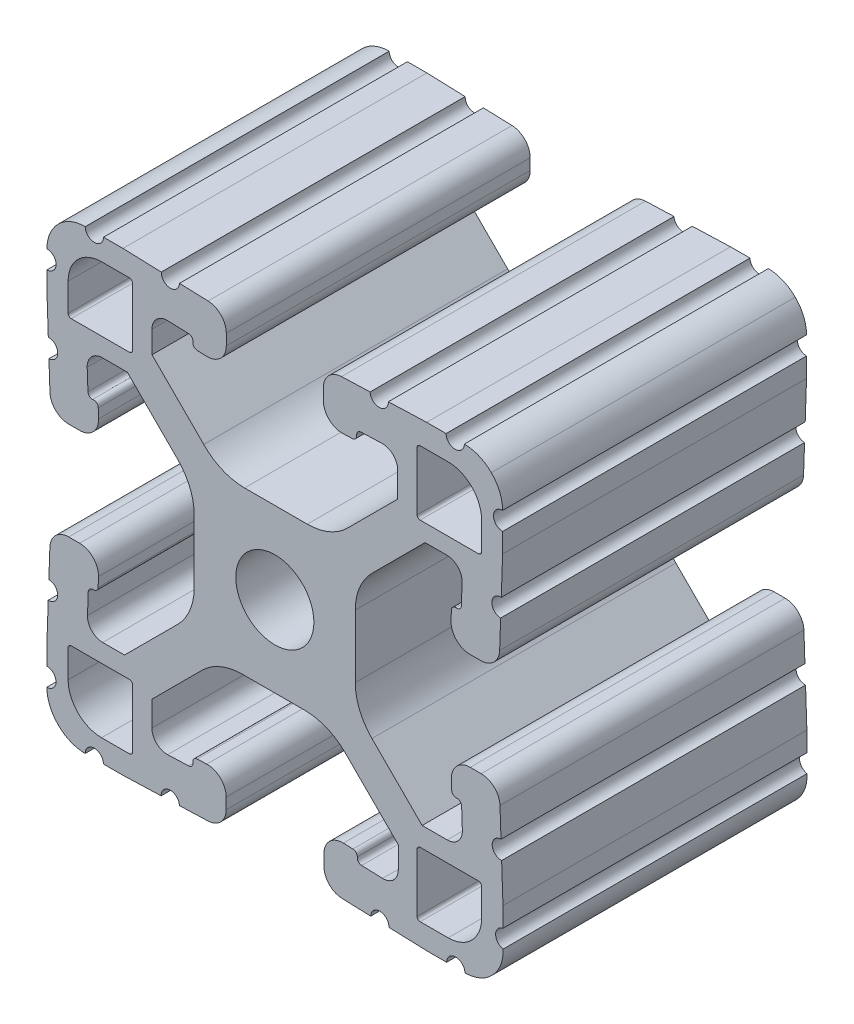
from build123d import *

# Parameters (mm, degrees)
SKETCH1_R           = 3.2639
BOSS_EXTRUDE1_DEPTH = 25.4


with BuildPart() as part:
    # Sketch1 → Boss-Extrude1 (new body)
    with BuildSketch(Plane(origin=(0, 0, -25.4), x_dir=(-1, 0, 0), z_dir=(0, 0, -1))):
        with BuildLine():
            Line((-88.043721549, 91.862643967), (-86.29674679, 91.923648859))
            ThreePointArc((-86.29674679, 91.923648859), (-85.370208675, 91.567983831), (-84.982425017, 90.654422489))
            Line((-84.982425017, 90.654422489), (-84.982425017, 88.800173916))
            Line((-84.982425017, 88.800173916), (-89.306565884, 84.476033049))
            ThreePointArc((-89.306565884, 84.476033049), (-90.866149908, 83.406077005), (-92.719610366, 83.029523439))
            Line((-92.719610366, 83.029523439), (-97.961628589, 83.029523439))
            ThreePointArc((-97.961628589, 83.029523439), (-99.779298356, 83.391080435), (-101.320244378, 84.42070765))
            Line((-101.320244378, 84.42070765), (-105.516001761, 88.616465033))
            Line((-105.516001761, 88.616465033), (-105.516001761, 90.731330035))
            ThreePointArc((-105.516001761, 90.731330035), (-105.128218103, 91.644891377), (-104.201679988, 92.000556406))
            Line((-104.201679988, 92.000556406), (-102.454705229, 91.939551513))
            ThreePointArc((-102.454705229, 91.939551513), (-102.193933359, 91.823448504), (-102.087001761, 91.558783602))
            ThreePointArc((-102.087001761, 91.558783602), (-102.010859042, 91.249291513), (-101.726191901, 91.105946874))
            Line((-101.726191901, 91.105946874), (-100.929727576, 91.078102142))
            ThreePointArc((-100.929727576, 91.078102142), (-99.780779944, 91.519102656), (-99.299905511, 92.651940638))
            Line((-99.299905511, 92.651940638), (-99.299905511, 93.566848638))
            ThreePointArc((-99.299905511, 93.566848638), (-99.741889517, 94.660796975), (-100.819746715, 95.140689345))
            Line((-100.819746715, 95.140689345), (-103.211918901, 95.224224422))
            ThreePointArc((-103.211918901, 95.224224422), (-104.000045777, 94.489281495), (-104.734990687, 95.277406522))
            Line((-104.734990687, 95.277406522), (-107.935905676, 95.389166912))
            Line((-107.935905676, 95.389166912), (-109.561454876, 95.389166912))
            ThreePointArc((-109.561454876, 95.389166912), (-110.323454876, 94.627166912), (-111.085454876, 95.389166912))
            ThreePointArc((-111.085454876, 95.389166912), (-112.308767787, 95.144035599), (-113.343184761, 94.446493225))
            ThreePointArc((-113.343184761, 94.446493225), (-114.04072548, 93.412075135), (-114.285854836, 92.188761832))
            ThreePointArc((-114.285854836, 92.188761832), (-113.523853616, 91.426762441), (-114.285853616, 90.664761832))
            Line((-114.285853616, 90.664761832), (-114.285853616, 89.039212632))
            Line((-114.285853616, 89.039212632), (-114.174093219, 85.838297643))
            ThreePointArc((-114.174093219, 85.838297643), (-113.385968191, 85.103352735), (-114.120911115, 84.315225857))
            Line((-114.120911115, 84.315225857), (-114.037376031, 81.923053667))
            ThreePointArc((-114.037376031, 81.923053667), (-113.55748366, 80.845196472), (-112.463535325, 80.403212468))
            Line((-112.463535325, 80.403212468), (-111.548627325, 80.403212468))
            ThreePointArc((-111.548627325, 80.403212468), (-110.415788905, 80.884087354), (-109.974788872, 82.033035791))
            Line((-109.974788872, 82.033035791), (-110.002634241, 82.829500094))
            ThreePointArc((-110.002634241, 82.829500094), (-110.118742417, 83.090261917), (-110.383401914, 83.197188))
            ThreePointArc((-110.383401914, 83.197188), (-110.693757401, 83.272605688), (-110.837665276, 83.557735272))
            Line((-110.837665276, 83.557735272), (-110.898671566, 85.304709982))
            ThreePointArc((-110.898671566, 85.304709982), (-110.543006925, 86.231248747), (-109.62944523, 86.61903277))
            Line((-109.62944523, 86.61903277), (-107.807161806, 86.61903277))
            Line((-107.807161806, 86.61903277), (-103.364925613, 82.176810793))
            ThreePointArc((-103.364925613, 82.176810793), (-102.335294479, 80.635862907), (-101.973736029, 78.81818963))
            Line((-101.973736029, 78.81818963), (-101.973736029, 73.576034207))
            ThreePointArc((-101.973736029, 73.576034207), (-102.335293752, 71.758362684), (-103.364922926, 70.21741573))
            Line((-103.364922926, 70.21741573), (-107.560683666, 66.021661704))
            Line((-107.560683666, 66.021661704), (-109.652436558, 66.021661704))
            ThreePointArc((-109.652436558, 66.021661704), (-110.565998503, 66.409445617), (-110.921663765, 67.335984343))
            Line((-110.921663765, 67.335984343), (-110.860658873, 69.082959102))
            ThreePointArc((-110.860658873, 69.082959102), (-110.744555864, 69.343730973), (-110.479890961, 69.45066257))
            ThreePointArc((-110.479890961, 69.45066257), (-110.173494703, 69.529390272), (-110.032185196, 69.812424443))
            Line((-110.032185196, 69.812424443), (-110.004340464, 70.608888768))
            ThreePointArc((-110.004340464, 70.608888768), (-110.445340978, 71.7578364), (-111.57817896, 72.238710833))
            Line((-111.57817896, 72.238710833), (-112.49308696, 72.238710833))
            ThreePointArc((-112.49308696, 72.238710833), (-113.587035297, 71.796726827), (-114.066927667, 70.718869629))
            Line((-114.066927667, 70.718869629), (-114.150462744, 68.326697443))
            ThreePointArc((-114.150462744, 68.326697443), (-113.415519817, 67.538570567), (-114.203644843, 66.803625657))
            Line((-114.203644843, 66.803625657), (-114.315405233, 63.602710668))
            Line((-114.315405233, 63.602710668), (-114.315405233, 61.962557497))
            ThreePointArc((-114.315405233, 61.962557497), (-113.701927281, 61.206106537), (-114.333208228, 60.464447842))
            ThreePointArc((-114.333208228, 60.464447842), (-114.113020459, 59.176546471), (-113.392816136, 58.086372941))
            ThreePointArc((-113.392816136, 58.086372941), (-112.358398046, 57.388832223), (-111.135084743, 57.143702867))
            ThreePointArc((-111.135084743, 57.143702867), (-110.373085352, 57.905704086), (-109.611084743, 57.143704086))
            Line((-109.611084743, 57.143704086), (-107.985535543, 57.143704086))
            Line((-107.985535543, 57.143704086), (-104.784620554, 57.255464483))
            ThreePointArc((-104.784620554, 57.255464483), (-104.049675645, 58.04358951), (-103.261548768, 57.308646586))
            Line((-103.261548768, 57.308646586), (-100.869376578, 57.39218167))
            ThreePointArc((-100.869376578, 57.39218167), (-99.791519383, 57.872074041), (-99.349535378, 58.966022376))
            Line((-99.349535378, 58.966022376), (-99.349535378, 59.880930376))
            ThreePointArc((-99.349535378, 59.880930376), (-99.830409811, 61.013768358), (-100.979357443, 61.454768873))
            Line((-100.979357443, 61.454768873), (-101.775821768, 61.42692414))
            ThreePointArc((-101.775821768, 61.42692414), (-102.036583684, 61.310816174), (-102.143509978, 61.046156762))
            ThreePointArc((-102.143509978, 61.046156762), (-102.222494916, 60.740061862), (-102.505377386, 60.598958297))
            Line((-102.505377386, 60.598958297), (-104.252352145, 60.537953405))
            ThreePointArc((-104.252352145, 60.537953405), (-105.17889026, 60.893618433), (-105.566673918, 61.807179775))
            Line((-105.566673918, 61.807179775), (-105.566673918, 63.629462758))
            Line((-105.566673918, 63.629462758), (-101.131142468, 68.064994208))
            ThreePointArc((-101.131142468, 68.064994208), (-99.590196446, 69.094621422), (-97.772526678, 69.456178419))
            Line((-97.772526678, 69.456178419), (-92.530356056, 69.456178419))
            ThreePointArc((-92.530356056, 69.456178419), (-90.712686289, 69.094621422), (-89.171740267, 68.064994208))
            Line((-89.171740267, 68.064994208), (-84.975982884, 63.869236825))
            Line((-84.975982884, 63.869236825), (-84.975982884, 61.781050107))
            ThreePointArc((-84.975982884, 61.781050107), (-85.363766542, 60.867488765), (-86.290304657, 60.511823736))
            Line((-86.290304657, 60.511823736), (-88.037279416, 60.572828629))
            ThreePointArc((-88.037279416, 60.572828629), (-88.298051286, 60.688931638), (-88.404982884, 60.95359654))
            ThreePointArc((-88.404982884, 60.95359654), (-88.466593694, 61.278962759), (-88.759626911, 61.433204782))
            Line((-88.759626911, 61.433204782), (-89.556091237, 61.461049514))
            ThreePointArc((-89.556091237, 61.461049514), (-90.705038868, 61.020049), (-91.185913301, 59.887211018))
            Line((-91.185913301, 59.887211018), (-91.185913301, 58.972303018))
            ThreePointArc((-91.185913301, 58.972303018), (-90.743929295, 57.878354681), (-89.666072098, 57.398462311))
            Line((-89.666072098, 57.398462311), (-87.273899911, 57.314927234))
            ThreePointArc((-87.273899911, 57.314927234), (-86.485773036, 58.049870161), (-85.750828126, 57.261745135))
            Line((-85.750828126, 57.261745135), (-82.549913136, 57.149984745))
            Line((-82.549913136, 57.149984745), (-80.924363936, 57.149984745))
            ThreePointArc((-80.924363936, 57.149984745), (-80.162363936, 57.911984745), (-79.400363936, 57.149984745))
            ThreePointArc((-79.400363936, 57.149984745), (-78.177051025, 57.395116058), (-77.142634052, 58.092658432))
            ThreePointArc((-77.142634052, 58.092658432), (-76.445094372, 59.127074031), (-76.199963977, 60.350384428))
            ThreePointArc((-76.199963977, 60.350384428), (-76.961961268, 61.112385783), (-76.199961268, 61.874384428))
            Line((-76.199961268, 61.874384428), (-76.199961268, 63.499933628))
            Line((-76.199961268, 63.499933628), (-76.311721666, 66.700848617))
            ThreePointArc((-76.311721666, 66.700848617), (-77.099846694, 67.435793525), (-76.364903769, 68.223920403))
            Line((-76.364903769, 68.223920403), (-76.448438853, 70.616092593))
            ThreePointArc((-76.448438853, 70.616092593), (-76.928331225, 71.693949788), (-78.02227956, 72.135933792))
            Line((-78.02227956, 72.135933792), (-78.93718756, 72.135933792))
            ThreePointArc((-78.93718756, 72.135933792), (-80.07002598, 71.655058906), (-80.511026012, 70.506110469))
            Line((-80.511026012, 70.506110469), (-80.483180643, 69.709646166))
            ThreePointArc((-80.483180643, 69.709646166), (-80.367072468, 69.448884343), (-80.102412971, 69.34195826))
            ThreePointArc((-80.102412971, 69.34195826), (-79.796317908, 69.262973649), (-79.655214052, 68.980091239))
            Line((-79.655214052, 68.980091239), (-79.594207761, 67.233116529))
            ThreePointArc((-79.594207761, 67.233116529), (-79.949872402, 66.306577764), (-80.863434097, 65.918793741))
            Line((-80.863434097, 65.918793741), (-82.685717521, 65.918793741))
            Line((-82.685717521, 65.918793741), (-87.121258001, 70.35431293))
            ThreePointArc((-87.121258001, 70.35431293), (-88.150863946, 71.895196205), (-88.512450271, 73.712794894))
            Line((-88.512450271, 73.712794894), (-88.512606864, 78.954950317))
            ThreePointArc((-88.512606864, 78.954950317), (-88.151076291, 80.772698182), (-87.121419968, 82.313710679))
            Line((-87.121419968, 82.313710679), (-82.925659228, 86.509464706))
            Line((-82.925659228, 86.509464706), (-80.837473527, 86.509464706))
            ThreePointArc((-80.837473527, 86.509464706), (-79.923911584, 86.121680793), (-79.568246321, 85.195142068))
            Line((-79.568246321, 85.195142068), (-79.629251214, 83.448167309))
            ThreePointArc((-79.629251214, 83.448167309), (-79.745354223, 83.187395438), (-80.010019125, 83.080463841))
            ThreePointArc((-80.010019125, 83.080463841), (-80.335385344, 83.018853031), (-80.489627367, 82.725819813))
            Line((-80.489627367, 82.725819813), (-80.5174721, 81.929355488))
            ThreePointArc((-80.5174721, 81.929355488), (-80.076471586, 80.780407856), (-78.943633603, 80.299533423))
            Line((-78.943633603, 80.299533423), (-78.028725603, 80.299533423))
            ThreePointArc((-78.028725603, 80.299533423), (-76.934777267, 80.741517429), (-76.454884897, 81.819374627))
            Line((-76.454884897, 81.819374627), (-76.37134982, 84.211546813))
            ThreePointArc((-76.37134982, 84.211546813), (-77.106292747, 84.999673689), (-76.31816772, 85.734618599))
            Line((-76.31816772, 85.734618599), (-76.20640733, 88.935533588))
            Line((-76.20640733, 88.935533588), (-76.20640733, 90.561082788))
            ThreePointArc((-76.20640733, 90.561082788), (-76.96840733, 91.323083398), (-76.206406111, 92.085082788))
            ThreePointArc((-76.206406111, 92.085082788), (-76.451535467, 93.308396091), (-77.149076185, 94.342814181))
            ThreePointArc((-77.149076185, 94.342814181), (-78.183493159, 95.040356555), (-79.40680607, 95.285487868))
            ThreePointArc((-79.40680607, 95.285487868), (-80.16880607, 94.523487868), (-80.93080607, 95.285487868))
            Line((-80.93080607, 95.285487868), (-82.55635527, 95.285487868))
            Line((-82.55635527, 95.285487868), (-85.757270259, 95.173727471))
            ThreePointArc((-85.757270259, 95.173727471), (-86.492215168, 94.385602444), (-87.280342045, 95.120545368))
            Line((-87.280342045, 95.120545368), (-89.672514235, 95.037010285))
            ThreePointArc((-89.672514235, 95.037010285), (-90.75037143, 94.557117913), (-91.192355435, 93.463169578))
            Line((-91.192355435, 93.463169578), (-91.192355435, 92.548261578))
            ThreePointArc((-91.192355435, 92.548261578), (-90.711481002, 91.415423596), (-89.56253337, 90.974423082))
            Line((-89.56253337, 90.974423082), (-88.766069045, 91.002267814))
            ThreePointArc((-88.766069045, 91.002267814), (-88.505307129, 91.11837578), (-88.398380835, 91.383035192))
            ThreePointArc((-88.398380835, 91.383035192), (-88.336765486, 91.708407548), (-88.043721549, 91.862643967))
        make_face()
        with Locations(Location((-95.25, 76.2, 0), (0, 0, 180))):  # turned: the seam where the file's is
            Circle(SKETCH1_R, mode=Mode.SUBTRACT)
        with BuildLine():
            Line((-83.357745393, 88.294108398), (-83.357745393, 93.170908398))
            ThreePointArc((-83.357745393, 93.170908398), (-83.283351492, 93.350512545), (-83.103748154, 93.424908398))
            Line((-83.103748154, 93.424908398), (-80.766975763, 93.424933798))
            ThreePointArc((-80.766975763, 93.424933798), (-78.791299784, 92.606600882), (-77.972945393, 90.630933798))
            Line((-77.972945393, 90.630933798), (-77.972945393, 88.294108398))
            ThreePointArc((-77.972945393, 88.294108398), (-78.047340271, 88.114503276), (-78.226945393, 88.040108398))
            Line((-78.226945393, 88.040108398), (-83.103745393, 88.040108398))
            ThreePointArc((-83.103745393, 88.040108398), (-83.283350516, 88.114503276), (-83.357745393, 88.294108398))
        make_face(mode=Mode.SUBTRACT)
        with BuildLine():
            Line((-83.357745393, 59.229091602), (-83.357745393, 64.105891602))
            ThreePointArc((-83.357745393, 64.105891602), (-83.283350516, 64.285496724), (-83.103745393, 64.359891602))
            Line((-83.103745393, 64.359891602), (-78.226945393, 64.359891602))
            ThreePointArc((-78.226945393, 64.359891602), (-78.047340271, 64.285496724), (-77.972945393, 64.105891602))
            Line((-77.972945393, 64.105891602), (-77.972945393, 61.769066202))
            ThreePointArc((-77.972945393, 61.769066202), (-78.791299784, 59.793399118), (-80.766975763, 58.975066202))
            Line((-80.766975763, 58.975066202), (-83.103748154, 58.975091602))
            ThreePointArc((-83.103748154, 58.975091602), (-83.283351492, 59.049487455), (-83.357745393, 59.229091602))
        make_face(mode=Mode.SUBTRACT)
        with BuildLine():
            Line((-107.142254607, 93.170908398), (-107.142254607, 88.294108398))
            ThreePointArc((-107.142254607, 88.294108398), (-107.216649484, 88.114503276), (-107.396254607, 88.040108398))
            Line((-107.396254607, 88.040108398), (-112.273054607, 88.040108398))
            ThreePointArc((-112.273054607, 88.040108398), (-112.452659729, 88.114503276), (-112.527054607, 88.294108398))
            Line((-112.527054607, 88.294108398), (-112.527054607, 90.630933798))
            ThreePointArc((-112.527054607, 90.630933798), (-111.708700216, 92.606600882), (-109.733024237, 93.424933798))
            Line((-109.733024237, 93.424933798), (-107.396251846, 93.424908398))
            ThreePointArc((-107.396251846, 93.424908398), (-107.216648508, 93.350512545), (-107.142254607, 93.170908398))
        make_face(mode=Mode.SUBTRACT)
        with BuildLine():
            Line((-107.142254607, 64.105891602), (-107.142254607, 59.229091602))
            ThreePointArc((-107.142254607, 59.229091602), (-107.216648508, 59.049487455), (-107.396251846, 58.975091602))
            Line((-107.396251846, 58.975091602), (-109.733024237, 58.975066202))
            ThreePointArc((-109.733024237, 58.975066202), (-111.708700216, 59.793399118), (-112.527054607, 61.769066202))
            Line((-112.527054607, 61.769066202), (-112.527054607, 64.105891602))
            ThreePointArc((-112.527054607, 64.105891602), (-112.452659729, 64.285496724), (-112.273054607, 64.359891602))
            Line((-112.273054607, 64.359891602), (-107.396254607, 64.359891602))
            ThreePointArc((-107.396254607, 64.359891602), (-107.216649484, 64.285496724), (-107.142254607, 64.105891602))
        make_face(mode=Mode.SUBTRACT)
    extrude(amount=-BOSS_EXTRUDE1_DEPTH)


solid = part.part
